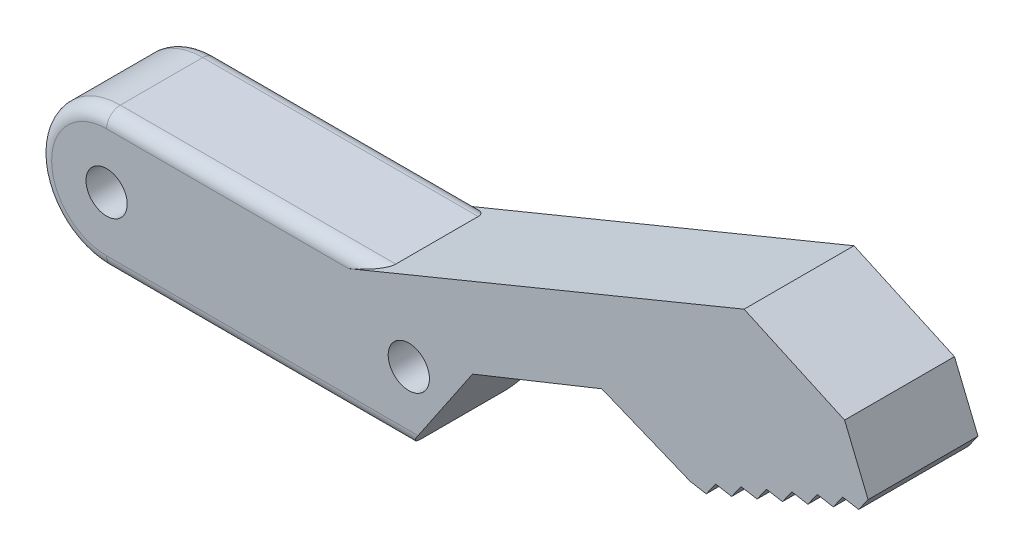
from build123d import *

# Parameters (mm, degrees)
SKETCH1_R           = 1.5
BOSS_EXTRUDE1_DEPTH = 8
FILLET1_R           = 1


with BuildPart() as part:
    # Sketch1 → Boss-Extrude1 (new body)
    with BuildSketch(Plane.XY):
        with BuildLine():
            Line((20.05, 5), (0, 5))
            ThreePointArc((0, 5), (-5, 0), (0, -5))
            Line((0, -5), (22, -5))
            Line((22, -5), (26.640289064, 1.862180818))
            ThreePointArc((26.640289064, 1.862180818), (24.800812017, 4.141914056), (22, 5))
            Line((22, 5), (20.05, 5))
        make_face()
        Circle(SKETCH1_R, mode=Mode.SUBTRACT)
        with Locations((22, 0)):
            Circle(SKETCH1_R, mode=Mode.SUBTRACT)
        with BuildLine():
            Line((46.409029503, 15.837507263), (20.05, 5))
            Line((20.05, 5), (22, 5))
            ThreePointArc((22, 5), (24.800812017, 4.141914056), (26.640289064, 1.862180818))
            Line((26.640289064, 1.862180818), (36.049561342, 5.638188326))
            Line((36.049561342, 5.638188326), (42.488975113, 3.018953392))
            Line((42.488975113, 3.018953392), (43.653419291, 2.816543521))
            Line((43.653419291, 2.816543521), (44.338731569, 3.779480217))
            Line((44.338731569, 3.779480217), (45.503175747, 3.577070346))
            Line((45.503175747, 3.577070346), (46.188488025, 4.540007042))
            Line((46.188488025, 4.540007042), (47.352932204, 4.337597171))
            Line((47.352932204, 4.337597171), (48.038244482, 5.300533868))
            Line((48.038244482, 5.300533868), (49.20268866, 5.098123997))
            Line((49.20268866, 5.098123997), (49.888000938, 6.061060693))
            Line((49.888000938, 6.061060693), (51.052445116, 5.858650822))
            Line((51.052445116, 5.858650822), (51.737757394, 6.821587519))
            Line((51.737757394, 6.821587519), (52.902201573, 6.619177648))
            Line((52.902201573, 6.619177648), (53.587513851, 7.582114344))
            Line((53.587513851, 7.582114344), (54.751958029, 7.379704473))
            Line((54.751958029, 7.379704473), (55.437270307, 8.34264117))
            Line((55.437270307, 8.34264117), (53.72608495, 12.504593197))
            Line((53.72608495, 12.504593197), (46.409029503, 15.837507263))
        make_face()
    extrude(amount=BOSS_EXTRUDE1_DEPTH)

    # Fillet1
    fillet1_edges = [part.edges().sort_by_distance(p)[0] for p in [
        (11, -5, 8),
        (11, -5, 0),
        (-5, 0, 0),
        (10.025, 5, 0),
        (10.025, 5, 8),
        (-5, 0, 8),
    ]]
    fillet(fillet1_edges, radius=FILLET1_R)


solid = part.part
